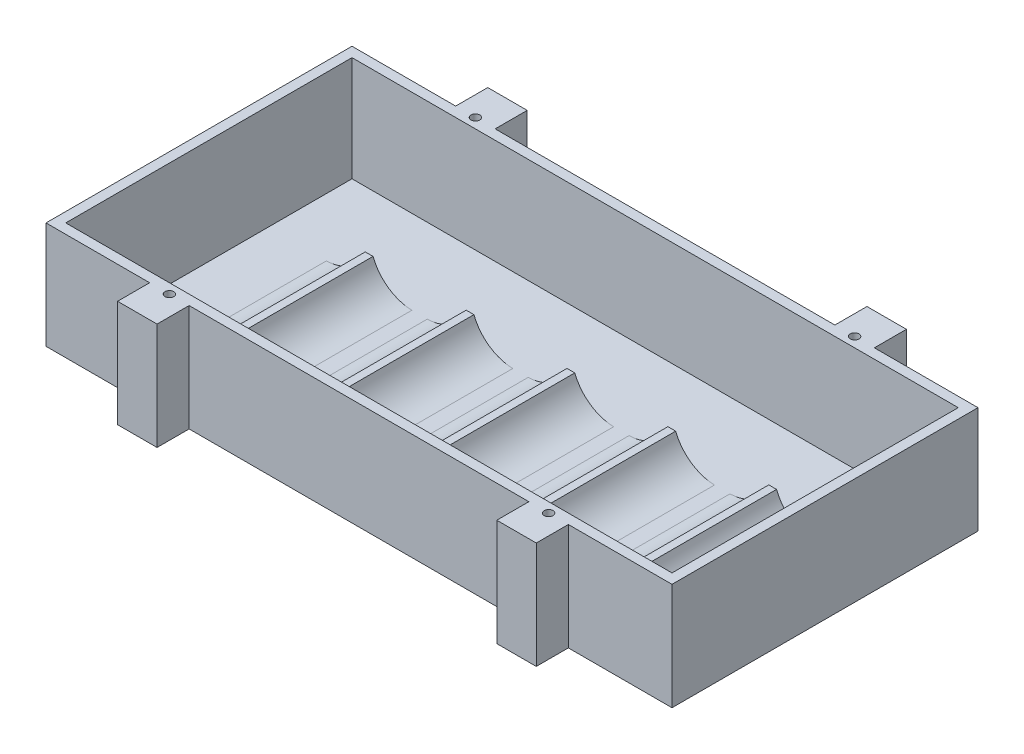
from build123d import *

# Parameters (mm, degrees)
SKETCH1_W                 = 161.08
SKETCH1_H                 = 78.74
BOSS_EXTRUDE1_DEPTH       = 0.508
SKETCH1_3_W               = 161.08
SKETCH1_3_H               = 8.255
SKETCH1_3_H_2             = 78.74
SKETCH1_3_W_2             = 156
SKETCH1_3_H_3             = 73.66
BOSS_EXTRUDE2_DEPTH       = 27
BOSS_EXTRUDE3_START       = 21.59
BOSS_EXTRUDE3_DEPTH       = 32.5
SKETCH1_4_W               = 161.08
SKETCH1_4_H               = 8.255
BOSS_EXTRUDE4_DEPTH       = 0.508
F_4_40_TAPPED_HOLE2_D     = 2.2606
F_4_40_TAPPED_HOLE2_DEPTH = 7.62
F_4_40_TAPPED_HOLE2_TIP   = 0.679152758
SKETCH11_W                = 87.42
SKETCH11_H                = 8.255
SKETCH11_W_2              = 26.67
CUT_EXTRUDE1_DEPTH        = 28.508


with BuildPart() as part:
    # Sketch1 → Boss-Extrude1 (new body)
    with BuildSketch(Plane(origin=(0, 0, 0), x_dir=(1, 0, 0), z_dir=(0, 1, 0))):
        with Locations((80.54, -39.37)):
            Rectangle(SKETCH1_W, SKETCH1_H)
    extrude(amount=-BOSS_EXTRUDE1_DEPTH)

    # Sketch1_3 → Boss-Extrude2 (add)
    with BuildSketch(Plane(origin=(0, 0, 0), x_dir=(1, 0, 0), z_dir=(0, 1, 0))):
        with Locations((80.54, 4.1275)):
            Rectangle(SKETCH1_3_W, SKETCH1_3_H)
        with Locations((80.54, -82.8675)):
            Rectangle(SKETCH1_3_W, SKETCH1_3_H)
        with Locations((80.54, -39.37)):
            Rectangle(SKETCH1_3_W, SKETCH1_3_H_2)
        with Locations((80.54, -39.37)):
            Rectangle(SKETCH1_3_W_2, SKETCH1_3_H_3, mode=Mode.SUBTRACT)
    extrude(amount=BOSS_EXTRUDE2_DEPTH)

    # Sketch5 → Boss-Extrude3 (add)
    with BuildSketch(Plane.XY.offset(2.54).offset(BOSS_EXTRUDE3_START)):
        with BuildLine():
            Line((29.54, 7), (27.54, 7))
            ThreePointArc((27.54, 7), (23.600043647, 1.985651932), (17.54, 0))
            Line((17.54, 0), (39.54, 0))
            ThreePointArc((39.54, 0), (33.479956353, 1.985651932), (29.54, 7))
        make_face()
        with BuildLine():
            Line((55.4988, 7), (53.4988, 7))
            ThreePointArc((53.4988, 7), (49.558843647, 1.985651932), (43.4988, 0))
            Line((43.4988, 0), (65.4988, 0))
            ThreePointArc((65.4988, 0), (59.438756353, 1.985651932), (55.4988, 7))
        make_face()
        with BuildLine():
            Line((81.4576, 7), (79.4576, 7))
            ThreePointArc((79.4576, 7), (75.517643647, 1.985651932), (69.4576, 0))
            Line((69.4576, 0), (91.4576, 0))
            ThreePointArc((91.4576, 0), (85.397556353, 1.985651932), (81.4576, 7))
        make_face()
        with BuildLine():
            Line((107.4164, 7), (105.4164, 7))
            ThreePointArc((105.4164, 7), (101.476443647, 1.985651932), (95.4164, 0))
            Line((95.4164, 0), (117.4164, 0))
            ThreePointArc((117.4164, 0), (111.356356353, 1.985651932), (107.4164, 7))
        make_face()
        with BuildLine():
            Line((133.3752, 7), (131.3752, 7))
            ThreePointArc((131.3752, 7), (127.435243647, 1.985651932), (121.3752, 0))
            Line((121.3752, 0), (143.3752, 0))
            ThreePointArc((143.3752, 0), (137.315156353, 1.985651932), (133.3752, 7))
        make_face()
    extrude(amount=BOSS_EXTRUDE3_DEPTH)

    # Sketch1_4 → Boss-Extrude4 (add)
    with BuildSketch(Plane(origin=(0, 0, 0), x_dir=(1, 0, 0), z_dir=(0, 1, 0))):
        with Locations((80.54, 4.1275)):
            Rectangle(SKETCH1_4_W, SKETCH1_4_H)
        with Locations((80.54, -82.8675)):
            Rectangle(SKETCH1_4_W, SKETCH1_4_H)
    extrude(amount=-BOSS_EXTRUDE4_DEPTH)

    # 4-40 Tapped Hole2
    with Locations(Plane(origin=(0, 27, 0), x_dir=(-1, 0, 0), z_dir=(0, 1, 0))):
        with Locations((-31.75, 0), (-129.33, 0), (-31.75, 78.74), (-129.33, 78.74)):
            Hole(F_4_40_TAPPED_HOLE2_D / 2, depth=F_4_40_TAPPED_HOLE2_DEPTH)
            with Locations((0, 0, -(F_4_40_TAPPED_HOLE2_DEPTH + F_4_40_TAPPED_HOLE2_TIP / 2))):  # 118° drill point
                Cone(0, F_4_40_TAPPED_HOLE2_D / 2, F_4_40_TAPPED_HOLE2_TIP, mode=Mode.SUBTRACT)

    # Sketch11 → Cut-Extrude1 (cut, through all)
    with BuildSketch(Plane(origin=(0, 27, 0), x_dir=(1, 0, 0), z_dir=(0, 1, 0))):
        with Locations((80.54, 4.1275)):
            Rectangle(SKETCH11_W, SKETCH11_H)
        with Locations((80.54, -82.8675)):
            Rectangle(SKETCH11_W, SKETCH11_H)
        with Locations((13.335, 4.1275)):
            Rectangle(SKETCH11_W_2, SKETCH11_H)
        with Locations((147.745, 4.1275)):
            Rectangle(SKETCH11_W_2, SKETCH11_H)
        with Locations((147.745, -82.8675)):
            Rectangle(SKETCH11_W_2, SKETCH11_H)
        with Locations((13.335, -82.8675)):
            Rectangle(SKETCH11_W_2, SKETCH11_H)
    extrude(amount=-CUT_EXTRUDE1_DEPTH, mode=Mode.SUBTRACT)


solid = part.part
